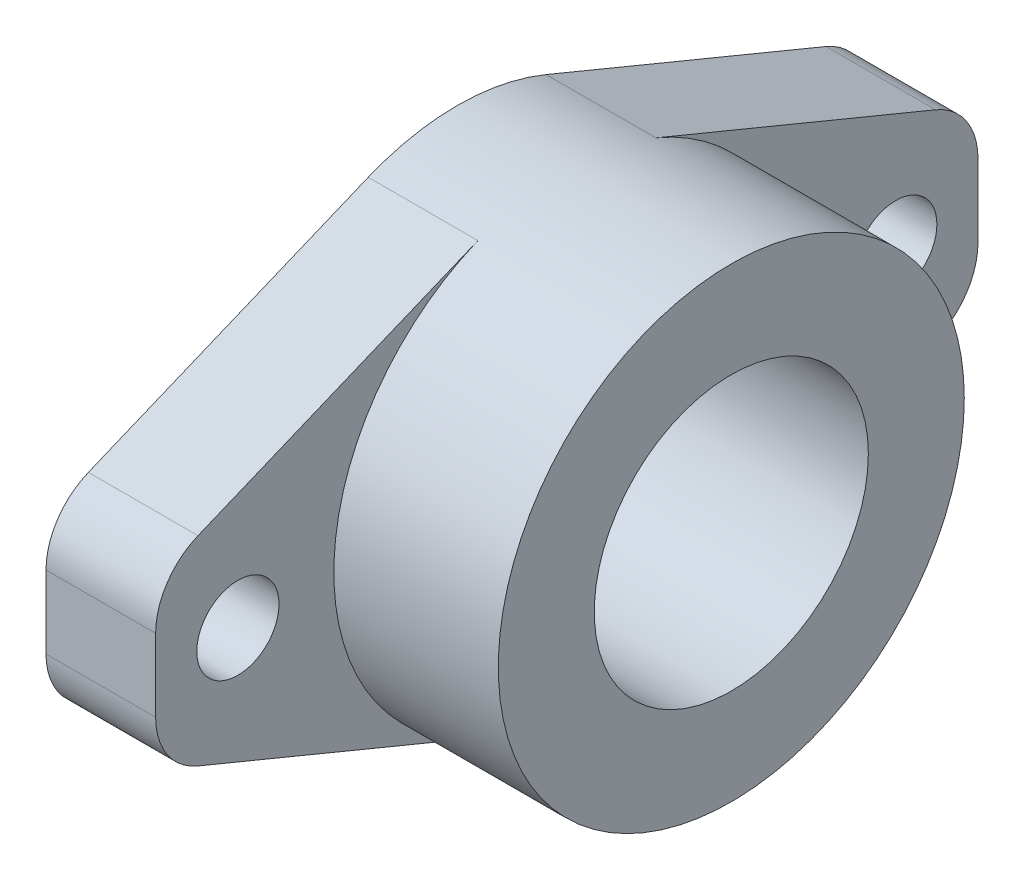
from build123d import *

# Parameters (mm, degrees)
SKETCH1_R           = 10
SKETCH1_R_2         = 3
BOSS_EXTRUDE1_DEPTH = 8
SKETCH3_R           = 17
SKETCH3_R_2         = 10
BOSS_EXTRUDE2_DEPTH = 20
FILLET1_R           = 5


with BuildPart() as part:
    # Sketch1 → Boss-Extrude1 (new body)
    with BuildSketch(Plane(origin=(0, 0, 0), x_dir=(0, 0, -1), z_dir=(1, 0, 0))):
        with BuildLine():
            Line((30, -6), (30, 6))
            Line((30, 6), (6.490927502, 15.712029155))
            ThreePointArc((6.490927502, 15.712029155), (0, 17), (-6.490927502, 15.712029155))
            Line((-6.490927502, 15.712029155), (-30, 6))
            Line((-30, 6), (-30, -6))
            Line((-30, -6), (-6.490927502, -15.712029155))
            ThreePointArc((-6.490927502, -15.712029155), (0, -17), (6.490927502, -15.712029155))
            Line((6.490927502, -15.712029155), (30, -6))
        make_face()
        Circle(SKETCH1_R, mode=Mode.SUBTRACT)
        with Locations((-24, 0)):
            Circle(SKETCH1_R_2, mode=Mode.SUBTRACT)
        with Locations((24, 0)):
            Circle(SKETCH1_R_2, mode=Mode.SUBTRACT)
    extrude(amount=BOSS_EXTRUDE1_DEPTH)

    # Sketch3 → Boss-Extrude2 (add)
    with BuildSketch(Plane(origin=(0, 0, 0), x_dir=(0, 0, -1), z_dir=(1, 0, 0))):
        Circle(SKETCH3_R)
        Circle(SKETCH3_R_2, mode=Mode.SUBTRACT)
    extrude(amount=BOSS_EXTRUDE2_DEPTH)

    # Fillet1
    fillet1_edges = [part.edges().sort_by_distance(p)[0] for p in [
        (4, 6, -30),
        (4, -6, -30),
        (4, -6, 30),
        (4, 6, 30),
    ]]
    fillet(fillet1_edges, radius=FILLET1_R)


solid = part.part
